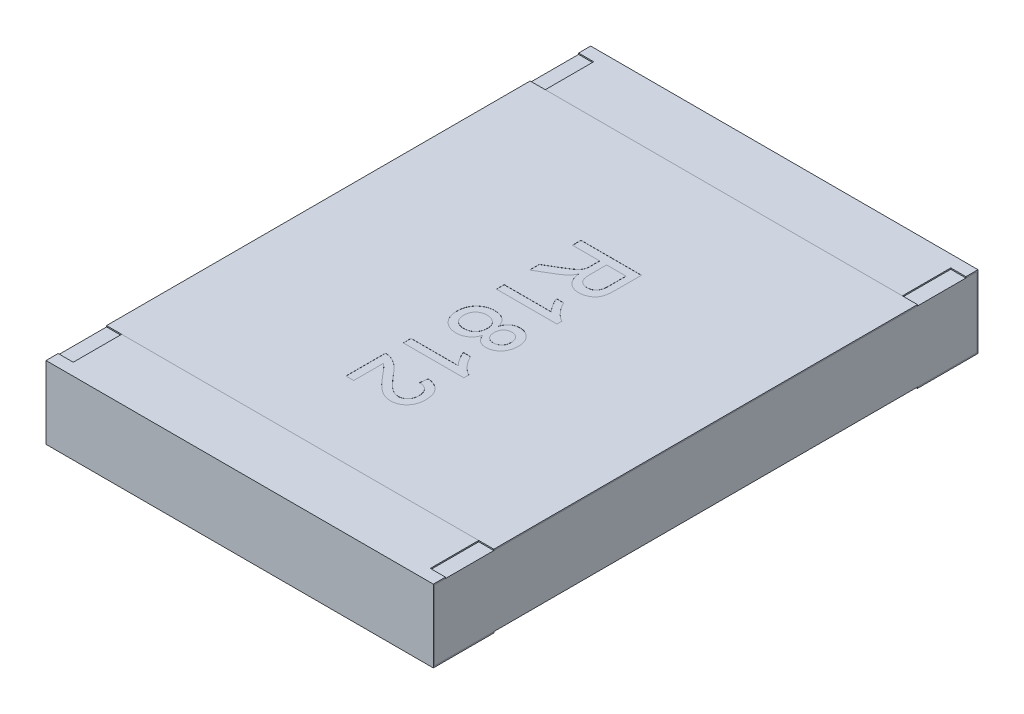
from build123d import *

# Parameters (mm, degrees)
BOSS_EXTRUDE2_DEPTH   = 1.6
BOSS_EXTRUDE2_2_DEPTH = 1.6
BOSS_EXTRUDE3_START   = -1.6
SKETCH5_W             = 4.48
SKETCH5_H             = 0.58
BOSS_EXTRUDE3_DEPTH   = 3.2
SKETCH6_W             = 0.125
SKETCH6_H             = 0.4
CUT_EXTRUDE1_DEPTH    = 0.01
SKETCH7_W             = 3.2
SKETCH7_H             = 3.5
BOSS_EXTRUDE4_DEPTH   = 0.01
TEXT1812_DEPTH        = 0.001


with BuildPart() as part:
    # Sketch4 → Boss-Extrude2 (new body, symmetric)
    with BuildSketch(Plane(origin=(0, 0, 0), x_dir=(0, 0, -1), z_dir=(1, 0, 0))):
        Polygon((-2.25, 0.3), (-2.25, -0.3), (-1.75, -0.3), (-1.75, -0.29), (-2.24, -0.29), (-2.24, 0.29), (-1.75, 0.29), (-1.75, 0.3), align=None)
    extrude(amount=BOSS_EXTRUDE2_DEPTH, both=True)


with BuildPart() as body_2:
    # Sketch4 → Boss-Extrude2 2 (new body, symmetric)
    with BuildSketch(Plane(origin=(0, 0, 0), x_dir=(0, 0, -1), z_dir=(1, 0, 0))):
        Polygon((1.75, 0.3), (2.25, 0.3), (2.25, -0.3), (1.75, -0.3), (1.75, -0.29), (2.24, -0.29), (2.24, 0.29), (1.75, 0.29), align=None)
    extrude(amount=BOSS_EXTRUDE2_2_DEPTH, both=True)


with BuildPart() as body_3:
    # Sketch5 → Boss-Extrude3 (new body)
    with BuildSketch(Plane(origin=(0, 0, 0), x_dir=(0, 0, -1), z_dir=(1, 0, 0)).offset(BOSS_EXTRUDE3_START)):
        Rectangle(SKETCH5_W, SKETCH5_H)
    extrude(amount=BOSS_EXTRUDE3_DEPTH)


with BuildPart() as cut_extrude1_tool:
    # Sketch6 → Cut-Extrude1 (new body)
    with BuildSketch(Plane(origin=(0, 0.3, 0), x_dir=(1, 0, 0), z_dir=(0, 1, 0))):
        with Locations((-1.5375, 1.95)):
            Rectangle(SKETCH6_W, SKETCH6_H)
        with Locations((1.5375, 1.95)):
            Rectangle(SKETCH6_W, SKETCH6_H)
        with Locations((1.5375, -1.95)):
            Rectangle(SKETCH6_W, SKETCH6_H)
        with Locations((-1.5375, -1.95)):
            Rectangle(SKETCH6_W, SKETCH6_H)
    extrude(amount=-CUT_EXTRUDE1_DEPTH)


with BuildPart() as part_1:
    add(part.part)

    # Cut-Extrude1: cut by cut_extrude1_tool
    add(cut_extrude1_tool.part, mode=Mode.SUBTRACT)


with BuildPart() as body_2_1:
    add(body_2.part)

    # Cut-Extrude1: cut by cut_extrude1_tool
    add(cut_extrude1_tool.part, mode=Mode.SUBTRACT)


with BuildPart() as body_4:
    # Sketch7 → Boss-Extrude4 (new body)
    with BuildSketch(Plane(origin=(0, 0.29, 0), x_dir=(1, 0, 0), z_dir=(0, 1, 0))):
        Rectangle(SKETCH7_W, SKETCH7_H)
    extrude(amount=BOSS_EXTRUDE4_DEPTH)

    # Sketch14 → TEXT1812 (cut)
    with BuildSketch(Plane(origin=(0, 0.3, 0), x_dir=(1, 0, 0), z_dir=(0, 1, 0))):
        with BuildLine():
            Line((-0.25, 0.820138052), (0.25, 0.820138052))
            Line((0.25, 0.820138052), (0.25, 0.603190936))
            add(Edge.make_bspline(
                [(0.25, 0.603190936), (0.249960163, 0.598082472), (0.249883063, 0.588195636), (0.249332125, 0.57385808), (0.248161656, 0.56050703), (0.246854386, 0.548058341), (0.244924176, 0.536533315), (0.242659692, 0.525926459), (0.239983333, 0.516278456), (0.236819773, 0.507515882), (0.233241826, 0.499385498), (0.228824875, 0.491851268), (0.223992823, 0.484590281), (0.218269952, 0.477889773), (0.212116317, 0.471456446), (0.205227709, 0.465510137), (0.197701412, 0.460021828), (0.18694151, 0.453249745), (0.17253828, 0.44612397), (0.154200832, 0.440042139), (0.134978762, 0.436153719), (0.121846978, 0.435735075), (0.115184295, 0.435522667)],
                knots=[0, 0, 0, 0, 1.5326e-05, 2.9661e-05, 4.3028e-05, 5.5527e-05, 6.7202e-05, 7.8066e-05, 8.8054e-05, 9.721e-05, 0.000105997, 0.000114656, 0.000123379, 0.000132125, 0.00014105, 0.000150068, 0.000159383, 0.00016897, 0.000188187, 0.000207412, 0.0002268, 0.000246768, 0.000246768, 0.000246768, 0.000246768], degree=3))
            add(Edge.make_bspline(
                [(0.115184295, 0.435522667), (0.110907215, 0.435620509), (0.10245969, 0.435813754), (0.090039553, 0.437294007), (0.078172662, 0.439972461), (0.066754852, 0.443406866), (0.055948764, 0.448108209), (0.045530439, 0.453552056), (0.035798164, 0.460305591), (0.026427897, 0.467846763), (0.017837878, 0.476613892), (0.00991265, 0.486373111), (0.003065461, 0.497370041), (-0.003087965, 0.509402317), (-0.008472636, 0.522491775), (-0.013000013, 0.536725455), (-0.016544481, 0.552052959), (-0.01831997, 0.562682204), (-0.019230769, 0.568134847)],
                knots=[0, 0, 0, 0, 1.283e-05, 2.5341e-05, 3.7443e-05, 4.9292e-05, 6.1049e-05, 7.2745e-05, 8.4496e-05, 9.6525e-05, 0.000108778, 0.000121245, 0.000134166, 0.00014756, 0.000161752, 0.000176576, 0.00019232, 0.000208902, 0.000208902, 0.000208902, 0.000208902], degree=3))
            add(Edge.make_bspline(
                [(-0.019230769, 0.568134847), (-0.021256287, 0.564104478), (-0.025089867, 0.556476431), (-0.03124439, 0.545954857), (-0.037334993, 0.536919777), (-0.041788652, 0.531708364), (-0.043870192, 0.529272667)],
                knots=[0, 0, 0, 0, 1.3529e-05, 2.5605e-05, 3.6551e-05, 4.6157e-05, 4.6157e-05, 4.6157e-05, 4.6157e-05], degree=3))
            add(Edge.make_bspline(
                [(-0.043870192, 0.529272667), (-0.048494022, 0.524541335), (-0.057976735, 0.514838153), (-0.074278364, 0.501596894), (-0.09220549, 0.488494826), (-0.105269317, 0.480628618), (-0.111979167, 0.476588372)],
                knots=[0, 0, 0, 0, 1.9831e-05, 4.0671e-05, 6.291e-05, 8.6395e-05, 8.6395e-05, 8.6395e-05, 8.6395e-05], degree=3))
            Line((-0.111979167, 0.476588372), (-0.25, 0.394557122))
            Line((-0.25, 0.394557122), (-0.25, 0.475386449))
            Line((-0.25, 0.475386449), (-0.14443109, 0.537686129))
            add(Edge.make_bspline(
                [(-0.14443109, 0.537686129), (-0.14072714, 0.539926204), (-0.133549493, 0.544267103), (-0.123065864, 0.550535866), (-0.113417718, 0.55668774), (-0.104312641, 0.56237486), (-0.095987375, 0.567901438), (-0.088193556, 0.572957121), (-0.081239279, 0.577930886), (-0.072863649, 0.583715439), (-0.063747422, 0.590689556), (-0.054441051, 0.598882955), (-0.046842147, 0.60648554), (-0.039501217, 0.61599741), (-0.032660963, 0.627800347), (-0.029482057, 0.637812242), (-0.027944712, 0.642654077)],
                knots=[0, 0, 0, 0, 1.2986e-05, 2.5165e-05, 3.6642e-05, 4.7312e-05, 5.7369e-05, 6.6619e-05, 7.5178e-05, 8.3014e-05, 9.7157e-05, 0.000109576, 0.000120201, 0.000129337, 0.000145574, 0.000160781, 0.000160781, 0.000160781, 0.000160781], degree=3))
            add(Edge.make_bspline(
                [(-0.027944712, 0.642654077), (-0.027578209, 0.644686433), (-0.026741472, 0.649326363), (-0.026194997, 0.657204952), (-0.025614988, 0.666750829), (-0.025631888, 0.673668889), (-0.025641026, 0.677409686)],
                knots=[0, 0, 0, 0, 6.191e-06, 1.4135e-05, 2.3663e-05, 3.4882e-05, 3.4882e-05, 3.4882e-05, 3.4882e-05], degree=3))
            Line((-0.025641026, 0.677409686), (-0.025641026, 0.749625231))
            Line((-0.025641026, 0.749625231), (-0.25, 0.749625231))
            Line((-0.25, 0.749625231), (-0.25, 0.820138052))
        make_face()
        with BuildLine():
            Line((0.032051282, 0.749625231), (0.032051282, 0.615710968))
            add(Edge.make_bspline(
                [(0.032051282, 0.615710968), (0.032156765, 0.608996088), (0.032353956, 0.596443249), (0.034025946, 0.578888794), (0.036712066, 0.5639013), (0.0405672, 0.551201022), (0.045943674, 0.540536686), (0.052623746, 0.531375018), (0.060751598, 0.523581014), (0.07009756, 0.517211165), (0.080294979, 0.512194114), (0.091082454, 0.50876917), (0.102226625, 0.506383032), (0.10982965, 0.506152362), (0.113681891, 0.506035488)],
                knots=[0, 0, 0, 0, 2.0141e-05, 3.7652e-05, 5.2837e-05, 6.5761e-05, 7.7318e-05, 8.8497e-05, 9.9618e-05, 0.000110925, 0.000122303, 0.000133579, 0.000144815, 0.000156355, 0.000156355, 0.000156355, 0.000156355], degree=3))
            add(Edge.make_bspline(
                [(0.113681891, 0.506035488), (0.116488464, 0.506128551), (0.121985715, 0.506310836), (0.130054155, 0.507266431), (0.137721037, 0.509124336), (0.14502689, 0.511577694), (0.151918204, 0.514855878), (0.158448379, 0.518750228), (0.164581222, 0.523397389), (0.170335414, 0.528720444), (0.175571167, 0.534832279), (0.180088486, 0.541813432), (0.183927233, 0.549608842), (0.186973919, 0.558227571), (0.189410772, 0.567642467), (0.191031932, 0.577907128), (0.192204997, 0.588974611), (0.192272821, 0.596643735), (0.192307692, 0.60058677)],
                knots=[0, 0, 0, 0, 8.423e-06, 1.6498e-05, 2.4321e-05, 3.205e-05, 3.9577e-05, 4.7169e-05, 5.4822e-05, 6.2617e-05, 7.0646e-05, 7.8897e-05, 8.7497e-05, 9.6653e-05, 0.000106273, 0.000116631, 0.000127803, 0.000139626, 0.000139626, 0.000139626, 0.000139626], degree=3))
            Line((0.192307692, 0.60058677), (0.192307692, 0.749625231))
            Line((0.192307692, 0.749625231), (0.032051282, 0.749625231))
        make_face(mode=Mode.SUBTRACT)
        with BuildLine():
            Line((-0.25, 0.121420103), (-0.25, 0.185522667))
            Line((-0.25, 0.185522667), (0.139623397, 0.185522667))
            add(Edge.make_bspline(
                [(0.139623397, 0.185522667), (0.136064182, 0.18921391), (0.128666742, 0.196885754), (0.118190939, 0.209849855), (0.107619408, 0.224316276), (0.097315673, 0.240045032), (0.08780582, 0.256201596), (0.079128194, 0.271767536), (0.071822591, 0.286525438), (0.067824115, 0.29624389), (0.065905449, 0.300907282)],
                knots=[0, 0, 0, 0, 1.5377e-05, 3.1959e-05, 4.9949e-05, 6.9117e-05, 8.8339e-05, 0.000106181, 0.000122576, 0.0001377, 0.0001377, 0.0001377, 0.0001377], degree=3))
            Line((0.065905449, 0.300907282), (0.125, 0.300907282))
            add(Edge.make_bspline(
                [(0.125, 0.300907282), (0.129125269, 0.292897082), (0.137255931, 0.277109451), (0.151298701, 0.254804943), (0.166521642, 0.233981285), (0.182921383, 0.214983192), (0.199684862, 0.197952612), (0.216599871, 0.183600694), (0.233046379, 0.171591923), (0.244515995, 0.165566895), (0.25, 0.162686129)],
                knots=[0, 0, 0, 0, 2.702e-05, 5.3254e-05, 7.8977e-05, 0.000104333, 0.000128484, 0.000150581, 0.000170841, 0.000189403, 0.000189403, 0.000189403, 0.000189403], degree=3))
            Line((0.25, 0.162686129), (0.25, 0.121420103))
            Line((0.25, 0.121420103), (-0.25, 0.121420103))
        make_face()
        with BuildLine():
            add(Edge.make_bspline(
                [(0.024238782, -0.13378823), (0.02539818, -0.130665703), (0.027670824, -0.124544947), (0.031729797, -0.1158501), (0.035977971, -0.107699651), (0.040722444, -0.100242732), (0.045841435, -0.093436845), (0.05125653, -0.0871692), (0.057051297, -0.081565416), (0.065251162, -0.074980652), (0.076469857, -0.068216491), (0.091129194, -0.062176059), (0.107150389, -0.058763139), (0.118206708, -0.058303624), (0.123898237, -0.058067076)],
                knots=[0, 0, 0, 0, 9.988e-06, 1.9579e-05, 2.8765e-05, 3.7545e-05, 4.6059e-05, 5.4294e-05, 6.2369e-05, 7.0206e-05, 8.5803e-05, 0.000101483, 0.000117572, 0.000134642, 0.000134642, 0.000134642, 0.000134642], degree=3))
            add(Edge.make_bspline(
                [(0.123898237, -0.058067076), (0.128278386, -0.058177319), (0.136876757, -0.058393729), (0.149495643, -0.060255828), (0.161579073, -0.063256878), (0.17314744, -0.067454985), (0.184113889, -0.072945813), (0.194640222, -0.079470394), (0.204558084, -0.087325527), (0.213797595, -0.096328987), (0.22236411, -0.1062004), (0.229759149, -0.117035487), (0.236018114, -0.128659024), (0.241127177, -0.14104805), (0.245166426, -0.154219013), (0.247909652, -0.168218536), (0.249656619, -0.182989598), (0.249883757, -0.193111384), (0.25, -0.198291435)],
                knots=[0, 0, 0, 0, 1.3135e-05, 2.5784e-05, 3.8173e-05, 5.0436e-05, 6.2619e-05, 7.4903e-05, 8.7527e-05, 0.00010049, 0.000113559, 0.000126672, 0.000139758, 0.000153094, 0.000166813, 0.000181015, 0.000195837, 0.000211373, 0.000211373, 0.000211373, 0.000211373], degree=3))
            add(Edge.make_bspline(
                [(0.25, -0.198291435), (0.249882531, -0.203504468), (0.249653714, -0.213658867), (0.247930845, -0.228508775), (0.245043208, -0.24259532), (0.240946379, -0.255910207), (0.235708336, -0.268474428), (0.229270093, -0.280205425), (0.221737839, -0.291223959), (0.213021747, -0.301248403), (0.203558906, -0.310369451), (0.193421, -0.318271978), (0.18284459, -0.325049724), (0.171765423, -0.330650513), (0.160057336, -0.334793997), (0.147940915, -0.337952263), (0.135272194, -0.339784203), (0.126675148, -0.340005584), (0.122295673, -0.340118359)],
                knots=[0, 0, 0, 0, 1.5637e-05, 3.0458e-05, 4.4778e-05, 5.8718e-05, 7.2186e-05, 8.5543e-05, 9.8796e-05, 0.000112147, 0.000125324, 0.000138167, 0.000150642, 0.00016296, 0.000175317, 0.000187828, 0.000200477, 0.000213612, 0.000213612, 0.000213612, 0.000213612], degree=3))
            add(Edge.make_bspline(
                [(0.122295673, -0.340118359), (0.116799676, -0.339934405), (0.10602306, -0.339573706), (0.090480034, -0.335923746), (0.076018484, -0.33018584), (0.062720931, -0.322088102), (0.050803482, -0.311507398), (0.040306374, -0.298570456), (0.031199936, -0.283280607), (0.026621629, -0.271915108), (0.024238782, -0.265999769)],
                knots=[0, 0, 0, 0, 1.6463e-05, 3.2281e-05, 4.7607e-05, 6.2981e-05, 7.8735e-05, 9.5177e-05, 0.000112783, 0.000131893, 0.000131893, 0.000131893, 0.000131893], degree=3))
            add(Edge.make_bspline(
                [(0.024238782, -0.265999769), (0.022972264, -0.269732885), (0.020490437, -0.277048174), (0.015654785, -0.287383461), (0.010491973, -0.297113151), (0.004755578, -0.306228756), (-0.001623653, -0.314599312), (-0.008616028, -0.322282606), (-0.016120459, -0.329326123), (-0.024261073, -0.335620803), (-0.032853908, -0.341246952), (-0.041930308, -0.346045678), (-0.051322704, -0.350181491), (-0.061196276, -0.353475863), (-0.071409343, -0.356231758), (-0.082118687, -0.357962321), (-0.093157345, -0.359110367), (-0.100658015, -0.359268713), (-0.104467147, -0.359349128)],
                knots=[0, 0, 0, 0, 1.1818e-05, 2.3157e-05, 3.4181e-05, 4.4851e-05, 5.5428e-05, 6.571e-05, 7.5985e-05, 8.6264e-05, 9.6542e-05, 0.000106759, 0.000117031, 0.000127293, 0.000137958, 0.000148727, 0.0001598, 0.000171225, 0.000171225, 0.000171225, 0.000171225], degree=3))
            add(Edge.make_bspline(
                [(-0.104467147, -0.359349128), (-0.109716763, -0.359221748), (-0.120058905, -0.358970799), (-0.135239829, -0.356765568), (-0.149823668, -0.353429704), (-0.163746516, -0.348562926), (-0.177026708, -0.34235648), (-0.189596023, -0.334653642), (-0.201582432, -0.325688212), (-0.212864831, -0.31546059), (-0.222998595, -0.303955828), (-0.232020834, -0.291602385), (-0.239541591, -0.278264895), (-0.245775203, -0.264115061), (-0.25060455, -0.249076997), (-0.253986549, -0.233172259), (-0.256000272, -0.216405524), (-0.256271764, -0.204940973), (-0.256410256, -0.199092718)],
                knots=[0, 0, 0, 0, 1.5741e-05, 3.1011e-05, 4.5928e-05, 6.0562e-05, 7.5169e-05, 8.9822e-05, 0.000104705, 0.00012002, 0.000135416, 0.000150623, 0.000165829, 0.000181256, 0.000196936, 0.000213123, 0.000229969, 0.000247512, 0.000247512, 0.000247512, 0.000247512], degree=3))
            add(Edge.make_bspline(
                [(-0.256410256, -0.199092718), (-0.256268784, -0.193245043), (-0.255991451, -0.181781631), (-0.254018827, -0.164999635), (-0.250483765, -0.149117441), (-0.24564863, -0.134099686), (-0.239586942, -0.11986266), (-0.23188486, -0.106624793), (-0.22294704, -0.094193386), (-0.212624421, -0.082854833), (-0.201347774, -0.072571993), (-0.189308416, -0.063489694), (-0.176534929, -0.055866044), (-0.163096374, -0.04957067), (-0.148943574, -0.044779656), (-0.134138206, -0.041415344), (-0.118689254, -0.039206413), (-0.108147498, -0.038961414), (-0.102764423, -0.038836307)],
                knots=[0, 0, 0, 0, 1.7542e-05, 3.4388e-05, 5.0597e-05, 6.6276e-05, 8.1664e-05, 9.692e-05, 0.000112127, 0.000127515, 0.000142829, 0.000157853, 0.000172678, 0.000187375, 0.000202294, 0.000217406, 0.000232874, 0.000249015, 0.000249015, 0.000249015, 0.000249015], degree=3))
            add(Edge.make_bspline(
                [(-0.102764423, -0.038836307), (-0.098756291, -0.038923199), (-0.090891642, -0.039093697), (-0.079356793, -0.040136759), (-0.068361168, -0.042210877), (-0.057847876, -0.044897192), (-0.047749211, -0.048259469), (-0.03826149, -0.052599902), (-0.029246667, -0.057654576), (-0.020751206, -0.063435044), (-0.012849932, -0.069981781), (-0.005462304, -0.077077617), (0.001111121, -0.08496864), (0.007217111, -0.093354514), (0.012370618, -0.102608228), (0.017102053, -0.11237502), (0.021136528, -0.122825771), (0.023194341, -0.130097481), (0.024238782, -0.13378823)],
                knots=[0, 0, 0, 0, 1.2026e-05, 2.3597e-05, 3.4697e-05, 4.5556e-05, 5.6135e-05, 6.6579e-05, 7.6804e-05, 8.7111e-05, 9.7357e-05, 0.000107557, 0.000117791, 0.00012813, 0.000138628, 0.000149514, 0.000160675, 0.000172178, 0.000172178, 0.000172178, 0.000172178], degree=3))
        make_face()
        with BuildLine():
            add(Edge.make_bspline(
                [(0.123597756, -0.122169641), (0.120991462, -0.122227316), (0.115896151, -0.122340071), (0.108439177, -0.123222236), (0.101377018, -0.124866139), (0.094654968, -0.127040492), (0.088296098, -0.129892414), (0.082239417, -0.133270576), (0.07663087, -0.137420726), (0.071437279, -0.142122226), (0.066668381, -0.147339063), (0.062556899, -0.153204744), (0.059025979, -0.159608538), (0.056288833, -0.166610467), (0.053861642, -0.174031557), (0.05250548, -0.182130408), (0.051402828, -0.190715912), (0.05132298, -0.196651302), (0.051282051, -0.199693679)],
                knots=[0, 0, 0, 0, 7.818e-06, 1.5285e-05, 2.2477e-05, 2.954e-05, 3.6445e-05, 4.3353e-05, 5.0304e-05, 5.7325e-05, 6.4345e-05, 7.146e-05, 7.8766e-05, 8.6224e-05, 9.3986e-05, 0.000102138, 0.00011081, 0.00011993, 0.00011993, 0.00011993, 0.00011993], degree=3))
            add(Edge.make_bspline(
                [(0.051282051, -0.199693679), (0.051324337, -0.202668969), (0.051406793, -0.208470621), (0.052489104, -0.216861783), (0.053924062, -0.224795911), (0.05614596, -0.232164774), (0.05889885, -0.23906661), (0.06252784, -0.245281878), (0.066452675, -0.251180497), (0.072742354, -0.257998403), (0.081592622, -0.265219728), (0.093575839, -0.271508028), (0.106731646, -0.275410615), (0.115891397, -0.275810526), (0.120592949, -0.276015794)],
                knots=[0, 0, 0, 0, 8.919e-06, 1.7392e-05, 2.5348e-05, 3.308e-05, 4.0446e-05, 4.7577e-05, 5.4634e-05, 6.1654e-05, 7.5326e-05, 8.8677e-05, 0.000102023, 0.000116097, 0.000116097, 0.000116097, 0.000116097], degree=3))
            add(Edge.make_bspline(
                [(0.120592949, -0.276015794), (0.125459209, -0.275769041), (0.134981221, -0.275286208), (0.148650499, -0.271386583), (0.161030782, -0.264821224), (0.170071927, -0.257321211), (0.176621705, -0.250379712), (0.180791077, -0.244440906), (0.184339581, -0.238056667), (0.187237413, -0.231202697), (0.189574544, -0.223869085), (0.191107815, -0.216035965), (0.192183151, -0.207736251), (0.192265305, -0.20203452), (0.192307692, -0.199092718)],
                knots=[0, 0, 0, 0, 1.4581e-05, 2.8532e-05, 4.2242e-05, 5.6337e-05, 6.3567e-05, 7.082e-05, 7.8039e-05, 8.5443e-05, 9.3109e-05, 0.000101085, 0.000109358, 0.000118178, 0.000118178, 0.000118178, 0.000118178], degree=3))
            add(Edge.make_bspline(
                [(0.192307692, -0.199092718), (0.192266666, -0.196150595), (0.192186687, -0.190415071), (0.191079222, -0.182061141), (0.189687591, -0.17415413), (0.187456834, -0.166765006), (0.184533253, -0.159931479), (0.181018489, -0.153580971), (0.176892408, -0.147730213), (0.170652349, -0.140740292), (0.161895936, -0.133320994), (0.150029615, -0.126885425), (0.13713766, -0.122892917), (0.12816696, -0.122413719), (0.123597756, -0.122169641)],
                knots=[0, 0, 0, 0, 8.819e-06, 1.7193e-05, 2.5247e-05, 3.2883e-05, 4.0288e-05, 4.7506e-05, 5.462e-05, 6.1715e-05, 7.5578e-05, 8.88e-05, 0.000101982, 0.000115666, 0.000115666, 0.000115666, 0.000115666], degree=3))
        make_face(mode=Mode.SUBTRACT)
        with BuildLine():
            add(Edge.make_bspline(
                [(-0.1015625, -0.102938871), (-0.105675937, -0.103049031), (-0.113913647, -0.103269641), (-0.126143608, -0.105227298), (-0.138176392, -0.10849501), (-0.149918479, -0.112886247), (-0.161048518, -0.118818852), (-0.170904356, -0.126756126), (-0.179338866, -0.136610032), (-0.1862755, -0.148035155), (-0.191829654, -0.160403287), (-0.195726919, -0.173271752), (-0.198263034, -0.186339464), (-0.198566293, -0.195174995), (-0.198717949, -0.199593519)],
                knots=[0, 0, 0, 0, 1.2334e-05, 2.4701e-05, 3.7044e-05, 4.9693e-05, 6.2243e-05, 7.471e-05, 8.7421e-05, 0.000100958, 0.000114677, 0.000127983, 0.000141224, 0.00015447, 0.00015447, 0.00015447, 0.00015447], degree=3))
            add(Edge.make_bspline(
                [(-0.198717949, -0.199593519), (-0.198656227, -0.203237224), (-0.198536319, -0.210315904), (-0.197166117, -0.220634403), (-0.195087072, -0.230356764), (-0.192236359, -0.239527521), (-0.188336404, -0.248011721), (-0.183778167, -0.255947411), (-0.178269329, -0.263253844), (-0.171981829, -0.269927351), (-0.165028627, -0.27590595), (-0.157520547, -0.281010608), (-0.149712731, -0.285519096), (-0.141294279, -0.288974633), (-0.132494834, -0.291807703), (-0.123234593, -0.293789549), (-0.113548875, -0.295031596), (-0.106941658, -0.295173869), (-0.103565705, -0.295246564)],
                knots=[0, 0, 0, 0, 1.0925e-05, 2.1224e-05, 3.1164e-05, 4.0731e-05, 4.9965e-05, 5.9121e-05, 6.8136e-05, 7.7347e-05, 8.6581e-05, 9.5583e-05, 0.000104553, 0.000113575, 0.000122825, 0.000132255, 0.000141945, 0.000152069, 0.000152069, 0.000152069, 0.000152069], degree=3))
            add(Edge.make_bspline(
                [(-0.103565705, -0.295246564), (-0.100123487, -0.295171521), (-0.093384171, -0.2950246), (-0.083485869, -0.293813699), (-0.074062616, -0.291717781), (-0.065105205, -0.28875871), (-0.05652785, -0.28520408), (-0.048457959, -0.280665857), (-0.040966071, -0.275175891), (-0.03384257, -0.269137082), (-0.027392394, -0.262308351), (-0.021830619, -0.254765932), (-0.016918505, -0.246750449), (-0.01315053, -0.238018996), (-0.010132287, -0.228764055), (-0.007939188, -0.218941624), (-0.006598604, -0.208511664), (-0.006474251, -0.201367188), (-0.006410256, -0.197690474)],
                knots=[0, 0, 0, 0, 1.0324e-05, 2.0213e-05, 2.986e-05, 3.9236e-05, 4.8482e-05, 5.7675e-05, 6.6932e-05, 7.6307e-05, 8.566e-05, 9.5035e-05, 0.00010438, 0.000113797, 0.000123489, 0.000133549, 0.000143948, 0.000154973, 0.000154973, 0.000154973, 0.000154973], degree=3))
            add(Edge.make_bspline(
                [(-0.006410256, -0.197690474), (-0.006474999, -0.194113654), (-0.006601914, -0.187101973), (-0.007948541, -0.176915089), (-0.010024387, -0.167274409), (-0.013025373, -0.158279017), (-0.0168655, -0.149836917), (-0.021594505, -0.142025202), (-0.027127484, -0.134731707), (-0.033541909, -0.128173789), (-0.04056438, -0.122302884), (-0.047939309, -0.117027574), (-0.055878465, -0.112726115), (-0.064156655, -0.109065124), (-0.072957178, -0.106417709), (-0.08208906, -0.104384109), (-0.091680221, -0.103156797), (-0.098220261, -0.103012575), (-0.1015625, -0.102938871)],
                knots=[0, 0, 0, 0, 1.0725e-05, 2.1024e-05, 3.0769e-05, 4.0271e-05, 4.9414e-05, 5.8535e-05, 6.761e-05, 7.6818e-05, 8.5987e-05, 9.5046e-05, 0.000103967, 0.000113029, 0.000122153, 0.000131485, 0.000141076, 0.0001511, 0.0001511, 0.0001511, 0.0001511], degree=3))
        make_face(mode=Mode.SUBTRACT)
        with BuildLine():
            Line((-0.25, -0.647810666), (-0.25, -0.583708102))
            Line((-0.25, -0.583708102), (0.139623397, -0.583708102))
            add(Edge.make_bspline(
                [(0.139623397, -0.583708102), (0.136064182, -0.580016859), (0.128666742, -0.572345016), (0.118190939, -0.559380915), (0.107619408, -0.544914494), (0.097315673, -0.529185737), (0.08780582, -0.513029173), (0.079128194, -0.497463233), (0.071822591, -0.482705331), (0.067824115, -0.472986879), (0.065905449, -0.468323487)],
                knots=[0, 0, 0, 0, 1.5377e-05, 3.1959e-05, 4.9949e-05, 6.9117e-05, 8.8339e-05, 0.000106181, 0.000122576, 0.0001377, 0.0001377, 0.0001377, 0.0001377], degree=3))
            Line((0.065905449, -0.468323487), (0.125, -0.468323487))
            add(Edge.make_bspline(
                [(0.125, -0.468323487), (0.129125269, -0.476333687), (0.137255931, -0.492121318), (0.151298701, -0.514425826), (0.166521642, -0.535249484), (0.182921383, -0.554247578), (0.199684862, -0.571278158), (0.216599871, -0.585630075), (0.233046379, -0.597638846), (0.244515995, -0.603663874), (0.25, -0.606544641)],
                knots=[0, 0, 0, 0, 2.702e-05, 5.3254e-05, 7.8977e-05, 0.000104333, 0.000128484, 0.000150581, 0.000170841, 0.000189403, 0.000189403, 0.000189403, 0.000189403], degree=3))
            Line((0.25, -0.606544641), (0.25, -0.647810666))
            Line((0.25, -0.647810666), (-0.25, -0.647810666))
        make_face()
        with BuildLine():
            Line((-0.185897436, -1.122169641), (-0.25, -1.122169641))
            Line((-0.25, -1.122169641), (-0.25, -0.795246564))
            add(Edge.make_bspline(
                [(-0.25, -0.795246564), (-0.246190204, -0.795239871), (-0.238583383, -0.795226507), (-0.227333376, -0.796513704), (-0.21623261, -0.798529712), (-0.209114131, -0.800809211), (-0.205528846, -0.801957301)],
                knots=[0, 0, 0, 0, 1.142e-05, 2.2802e-05, 3.392e-05, 4.5202e-05, 4.5202e-05, 4.5202e-05, 4.5202e-05], degree=3))
            add(Edge.make_bspline(
                [(-0.205528846, -0.801957301), (-0.199672194, -0.804080662), (-0.187747085, -0.808404174), (-0.170501435, -0.817130164), (-0.153461868, -0.827564398), (-0.139489569, -0.837550185), (-0.128408004, -0.846747108), (-0.11963342, -0.854331204), (-0.110764129, -0.862874534), (-0.101641984, -0.872221358), (-0.092266458, -0.882314952), (-0.082593861, -0.893154922), (-0.07280804, -0.904873388), (-0.066321448, -0.913053933), (-0.063000801, -0.917241756)],
                knots=[0, 0, 0, 0, 1.8675e-05, 3.8026e-05, 5.7849e-05, 7.8586e-05, 8.9474e-05, 0.000101045, 0.000113371, 0.000126404, 0.000140223, 0.000154696, 0.000169983, 0.000186016, 0.000186016, 0.000186016, 0.000186016], degree=3))
            add(Edge.make_bspline(
                [(-0.063000801, -0.917241756), (-0.057585784, -0.923675309), (-0.047158825, -0.936063523), (-0.031686185, -0.953557623), (-0.017318962, -0.969535636), (-0.003805341, -0.983743129), (0.008723604, -0.996296306), (0.020239487, -1.007224642), (0.03070637, -1.016622167), (0.040503108, -1.024374156), (0.049753955, -1.030914747), (0.058777584, -1.03645732), (0.06773162, -1.041076319), (0.076587728, -1.044923328), (0.085383783, -1.047965984), (0.094145409, -1.050039988), (0.102785672, -1.051446505), (0.108534999, -1.051587228), (0.111378205, -1.05165682)],
                knots=[0, 0, 0, 0, 2.5226e-05, 4.8575e-05, 7.0061e-05, 8.9685e-05, 0.000107391, 0.000123262, 0.00013731, 0.000149574, 0.000160717, 0.000171282, 0.000181316, 0.000190917, 0.000200229, 0.000209193, 0.000217905, 0.000226428, 0.000226428, 0.000226428, 0.000226428], degree=3))
            add(Edge.make_bspline(
                [(0.111378205, -1.05165682), (0.114188238, -1.05158722), (0.119701369, -1.051450669), (0.127769802, -1.050155075), (0.135539896, -1.048351505), (0.14287177, -1.045435681), (0.149982559, -1.041964976), (0.156647535, -1.037512946), (0.163032944, -1.032362907), (0.168969907, -1.02646638), (0.17454131, -1.02002663), (0.179166687, -1.01282871), (0.183368098, -1.005329522), (0.186646742, -0.997281212), (0.189173495, -0.988755464), (0.190933763, -0.979765949), (0.192071797, -0.970288668), (0.192227868, -0.963819629), (0.192307692, -0.960510987)],
                knots=[0, 0, 0, 0, 8.423e-06, 1.6525e-05, 2.4469e-05, 3.23e-05, 4.0139e-05, 4.8167e-05, 5.6286e-05, 6.4714e-05, 7.3243e-05, 8.1771e-05, 9.0332e-05, 9.9e-05, 0.000107778, 0.000116971, 0.00012645, 0.000136374, 0.000136374, 0.000136374, 0.000136374], degree=3))
            add(Edge.make_bspline(
                [(0.192307692, -0.960510987), (0.192227732, -0.957035547), (0.192071243, -0.950233857), (0.190936175, -0.940290531), (0.189191722, -0.930855108), (0.186569692, -0.921961239), (0.183136978, -0.913626712), (0.179045534, -0.905792441), (0.174196706, -0.898488383), (0.168565002, -0.891831421), (0.162430447, -0.885665003), (0.155494268, -0.880455735), (0.148121475, -0.875902122), (0.140077995, -0.8723099), (0.131540513, -0.86938033), (0.122382293, -0.867265754), (0.11264261, -0.866110042), (0.105972365, -0.865877967), (0.102564103, -0.865759384)],
                knots=[0, 0, 0, 0, 1.0424e-05, 2.0401e-05, 2.9987e-05, 3.9178e-05, 4.8162e-05, 5.6988e-05, 6.5655e-05, 7.4401e-05, 8.3113e-05, 9.1687e-05, 0.000100362, 0.000109057, 0.000118053, 0.000127407, 0.000137196, 0.000147425, 0.000147425, 0.000147425, 0.000147425], degree=3))
            Line((0.102564103, -0.865759384), (0.108974359, -0.80165682))
            add(Edge.make_bspline(
                [(0.108974359, -0.80165682), (0.114561103, -0.802312611), (0.125429633, -0.803588397), (0.141170053, -0.806767489), (0.15581619, -0.811225938), (0.169558239, -0.816576789), (0.182228095, -0.823235726), (0.193871977, -0.830955489), (0.20454309, -0.839730059), (0.213993267, -0.849712236), (0.222618938, -0.860519957), (0.229876147, -0.872421323), (0.236164414, -0.88514024), (0.241249058, -0.898767231), (0.245145041, -0.913296947), (0.247930691, -0.928706759), (0.249649875, -0.94501411), (0.249881626, -0.956199816), (0.25, -0.96191323)],
                knots=[0, 0, 0, 0, 1.6871e-05, 3.2822e-05, 4.8095e-05, 6.2751e-05, 7.6998e-05, 9.0943e-05, 0.000104601, 0.000118344, 0.000132109, 0.000146007, 0.000160072, 0.00017462, 0.000189563, 0.000205142, 0.000221557, 0.000238695, 0.000238695, 0.000238695, 0.000238695], degree=3))
            add(Edge.make_bspline(
                [(0.25, -0.96191323), (0.24990096, -0.967694987), (0.249708029, -0.978957883), (0.247735103, -0.995370035), (0.244659885, -1.010854223), (0.240382222, -1.02547242), (0.234732773, -1.039146964), (0.227928529, -1.051924671), (0.219852523, -1.063765084), (0.210540088, -1.074507461), (0.200369372, -1.084194825), (0.189509921, -1.092671914), (0.178049555, -1.099798704), (0.166021375, -1.105693536), (0.153347568, -1.110207264), (0.140075652, -1.113348511), (0.126237909, -1.11549276), (0.116795268, -1.115669328), (0.111979167, -1.115759384)],
                knots=[0, 0, 0, 0, 1.7338e-05, 3.3775e-05, 4.9509e-05, 6.4657e-05, 7.9389e-05, 9.3818e-05, 0.000108014, 0.000122289, 0.000136388, 0.000150092, 0.000163543, 0.000176803, 0.000190204, 0.000203808, 0.000217675, 0.000232111, 0.000232111, 0.000232111, 0.000232111], degree=3))
            add(Edge.make_bspline(
                [(0.111979167, -1.115759384), (0.107030663, -1.115624195), (0.097122734, -1.115353518), (0.082332055, -1.113161393), (0.067657262, -1.109632734), (0.052981733, -1.10473645), (0.038292684, -1.097922375), (0.023237391, -1.089530301), (0.007927337, -1.079041349), (-0.005185376, -1.069094265), (-0.016100688, -1.059728825), (-0.025104319, -1.051427486), (-0.034707985, -1.041825689), (-0.045099702, -1.03117877), (-0.056125829, -1.019268661), (-0.067952516, -1.006312397), (-0.080329296, -0.992052642), (-0.088782578, -0.982151676), (-0.093149038, -0.977037429)],
                knots=[0, 0, 0, 0, 1.484e-05, 2.9713e-05, 4.4751e-05, 6.0081e-05, 7.6038e-05, 9.3257e-05, 0.000111731, 0.000131664, 0.000142604, 0.000154866, 0.000168394, 0.000183339, 0.000199497, 0.000217082, 0.000235964, 0.000256139, 0.000256139, 0.000256139, 0.000256139], degree=3))
            add(Edge.make_bspline(
                [(-0.093149038, -0.977037429), (-0.096714295, -0.972657933), (-0.103512691, -0.964306909), (-0.113369606, -0.95242691), (-0.122404327, -0.941782759), (-0.1303383, -0.932139701), (-0.137487823, -0.92382447), (-0.143708014, -0.916658718), (-0.149086369, -0.910713598), (-0.157337473, -0.901650567), (-0.169000351, -0.890084453), (-0.180421993, -0.881630873), (-0.185897436, -0.877578294)],
                knots=[0, 0, 0, 0, 1.6942e-05, 3.2305e-05, 4.6309e-05, 5.8826e-05, 6.9766e-05, 7.9207e-05, 8.7292e-05, 9.3814e-05, 0.000115985, 0.0001364, 0.0001364, 0.0001364, 0.0001364], degree=3))
            Line((-0.185897436, -0.877578294), (-0.185897436, -1.122169641))
        make_face()
    extrude(amount=-TEXT1812_DEPTH, mode=Mode.SUBTRACT)


solid = Compound([body_3.part, part_1.part, body_2_1.part, body_4.part])
